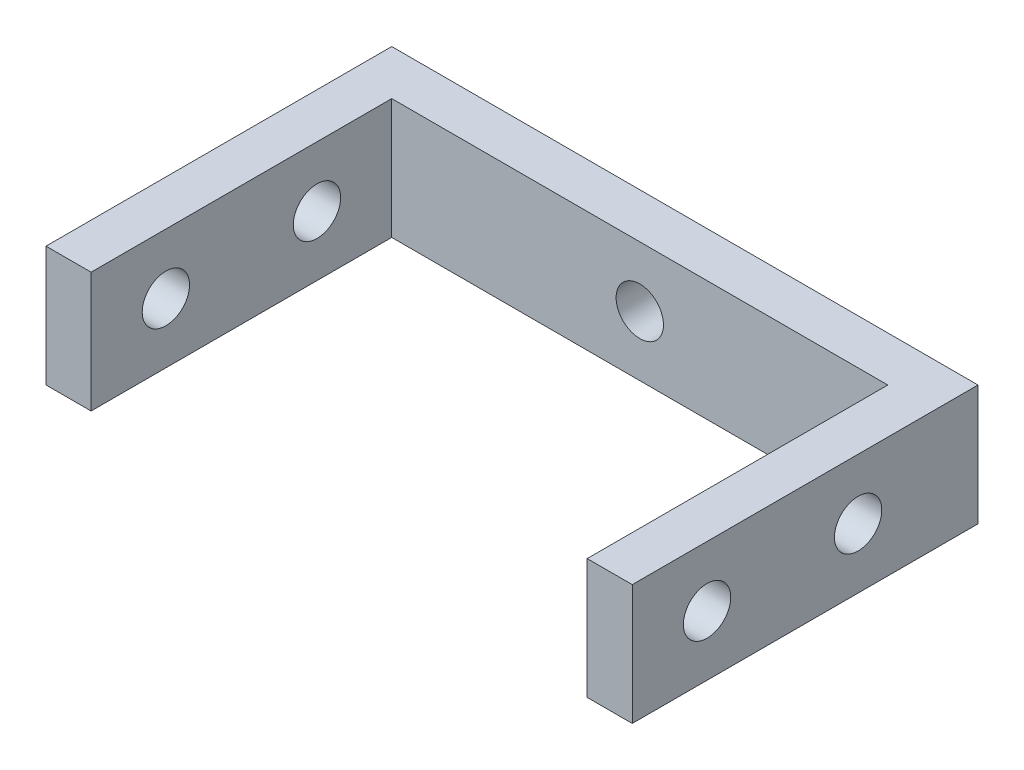
from build123d import *

# Parameters (mm, degrees)
SKETCH1_W           = 39
SKETCH1_H           = 8
BOSS_EXTRUDE1_DEPTH = 3
SKETCH2_W           = 3
SKETCH2_H           = 8
BOSS_EXTRUDE2_DEPTH = 20
SKETCH3_R           = 1.575
CUT_EXTRUDE1_DEPTH  = 40
SKETCH4_R           = 1.575
CUT_EXTRUDE2_DEPTH  = 3


with BuildPart() as part:
    # Sketch1 → Boss-Extrude1 (new body)
    with BuildSketch(Plane.XY):
        Rectangle(SKETCH1_W, SKETCH1_H)
    extrude(amount=BOSS_EXTRUDE1_DEPTH)

    # Sketch2 → Boss-Extrude2 (add)
    with BuildSketch(Plane.XY.offset(3)):
        with Locations((-18, 0)):
            Rectangle(SKETCH2_W, SKETCH2_H)
        with Locations((18, 0)):
            Rectangle(SKETCH2_W, SKETCH2_H)
    extrude(amount=BOSS_EXTRUDE2_DEPTH)

    # Sketch3 → Cut-Extrude1 (cut, through all)
    with BuildSketch(Plane.ZY.offset(19.5)):
        with Locations((18.025, 0)):
            Circle(SKETCH3_R)
        with Locations((7.975, 0)):
            Circle(SKETCH3_R)
    extrude(amount=-CUT_EXTRUDE1_DEPTH, mode=Mode.SUBTRACT)

    # Sketch4 → Cut-Extrude2 (cut)
    with BuildSketch(Plane.XY.offset(3)):
        Circle(SKETCH4_R)
    extrude(amount=-CUT_EXTRUDE2_DEPTH, mode=Mode.SUBTRACT)


solid = part.part
